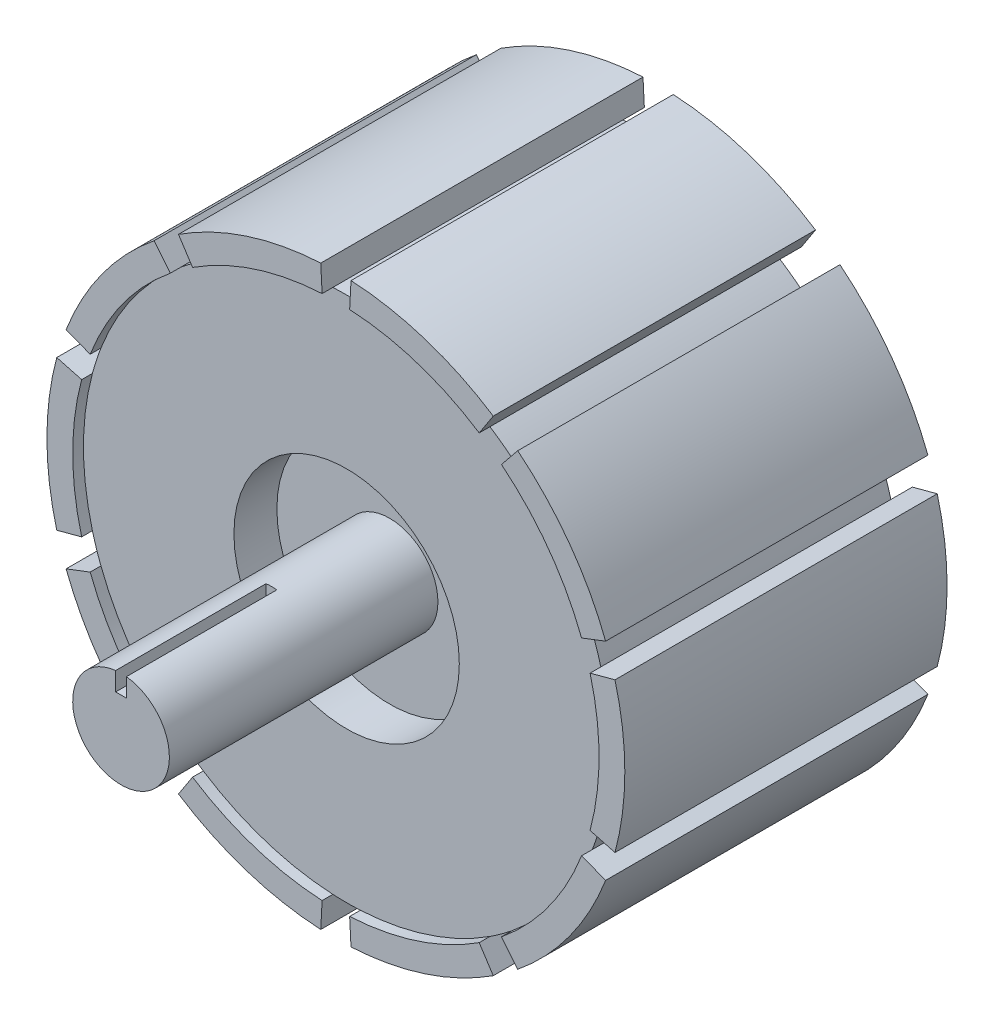
from build123d import *

# Parameters (mm, degrees)
SKETCH1_R           = 24.5
BOSS_EXTRUDE1_DEPTH = 30
SKETCH2_R           = 10.491597787
CUT_EXTRUDE1_DEPTH  = 5
BOSS_EXTRUDE3_DEPTH = 30
SKETCH6_R           = 24.5
CUT_EXTRUDE2_DEPTH  = 2
SKETCH7_R           = 24.5
CUT_EXTRUDE4_DEPTH  = 1
SKETCH4_R           = 4.5
BOSS_EXTRUDE4_DEPTH = 25
CUT_EXTRUDE5_DEPTH  = 14


with BuildPart() as part:
    # Sketch1 → Boss-Extrude1 (new body)
    with BuildSketch(Plane.XY):
        Circle(SKETCH1_R)
    extrude(amount=BOSS_EXTRUDE1_DEPTH)

    # Sketch2 → Cut-Extrude1 (cut)
    with BuildSketch(Plane.XY.offset(30)):
        Circle(SKETCH2_R)
    extrude(amount=-CUT_EXTRUDE1_DEPTH, mode=Mode.SUBTRACT)

    # Sketch5 → Boss-Extrude3 (add)
    with BuildSketch(Plane(origin=(0, 0, 0), x_dir=(-1, 0, 0), z_dir=(0, 0, -1))):
        with BuildLine():
            ThreePointArc((-1.28221594, -24.466424387), (-7.570916362, -23.300884649), (-13.343668945, -20.54742074))
            Line((-13.343668945, -20.54742074), (-14.650803863, -22.560229302))
            ThreePointArc((-14.650803863, -22.560229302), (-8.312557149, -25.583420288), (-1.407820766, -26.863135347))
            Line((-1.407820766, -26.863135347), (-1.28221594, -24.466424387))
        make_face()
        with BuildLine():
            ThreePointArc((13.343668945, -20.54742074), (7.570916362, -23.300884649), (1.28221594, -24.466424387))
            Line((1.28221594, -24.466424387), (1.407820766, -26.863135347))
            ThreePointArc((1.407820766, -26.863135347), (8.312557149, -25.583420288), (14.650803863, -22.560229302))
            Line((14.650803863, -22.560229302), (13.343668945, -20.54742074))
        make_face()
        with BuildLine():
            ThreePointArc((22.872725828, -8.780000752), (19.820916362, -14.400738681), (15.418337917, -19.040085501))
            Line((15.418337917, -19.040085501), (16.928705712, -20.905236734))
            ThreePointArc((16.928705712, -20.905236734), (21.762557149, -15.811423287), (25.113319378, -9.640082458))
            Line((25.113319378, -9.640082458), (22.872725828, -8.780000752))
        make_face()
        with BuildLine():
            Line((25.983400462, 6.962248231), (23.665178859, 6.341081103))
            ThreePointArc((23.665178859, 6.341081103), (24.290398124, 3.19789915), (24.5, 0))
            ThreePointArc((24.5, 0), (24.290398124, -3.19789915), (23.665178859, -6.341081103))
            Line((23.665178859, -6.341081103), (25.983400462, -6.962248231))
            ThreePointArc((25.983400462, -6.962248231), (26.9, 0), (25.983400462, 6.962248231))
        make_face()
        with BuildLine():
            Line((16.928705712, 20.905236734), (15.418337917, 19.040085501))
            ThreePointArc((15.418337917, 19.040085501), (19.820916362, 14.400738681), (22.872725828, 8.780000752))
            Line((22.872725828, 8.780000752), (25.113319378, 9.640082458))
            ThreePointArc((25.113319378, 9.640082458), (21.762557149, 15.811423287), (16.928705712, 20.905236734))
        make_face()
        with BuildLine():
            Line((1.407820766, 26.863135347), (1.28221594, 24.466424387))
            ThreePointArc((1.28221594, 24.466424387), (7.570916362, 23.300884649), (13.343668945, 20.54742074))
            Line((13.343668945, 20.54742074), (14.650803863, 22.560229302))
            ThreePointArc((14.650803863, 22.560229302), (8.312557149, 25.583420288), (1.407820766, 26.863135347))
        make_face()
        with BuildLine():
            Line((-14.650803863, 22.560229302), (-13.343668945, 20.54742074))
            ThreePointArc((-13.343668945, 20.54742074), (-7.570916362, 23.300884649), (-1.28221594, 24.466424387))
            Line((-1.28221594, 24.466424387), (-1.407820766, 26.863135347))
            ThreePointArc((-1.407820766, 26.863135347), (-8.312557149, 25.583420288), (-14.650803863, 22.560229302))
        make_face()
        with BuildLine():
            Line((-25.113319378, 9.640082458), (-22.872725828, 8.780000752))
            ThreePointArc((-22.872725828, 8.780000752), (-19.820916362, 14.400738681), (-15.418337917, 19.040085501))
            Line((-15.418337917, 19.040085501), (-16.928705712, 20.905236734))
            ThreePointArc((-16.928705712, 20.905236734), (-21.762557149, 15.811423287), (-25.113319378, 9.640082458))
        make_face()
        with BuildLine():
            ThreePointArc((-23.665178859, -6.341081103), (-24.5, 0), (-23.665178859, 6.341081103))
            Line((-23.665178859, 6.341081103), (-25.983400462, 6.962248231))
            ThreePointArc((-25.983400462, 6.962248231), (-26.9, 0), (-25.983400462, -6.962248231))
            Line((-25.983400462, -6.962248231), (-23.665178859, -6.341081103))
        make_face()
        with BuildLine():
            ThreePointArc((-15.418337917, -19.040085501), (-19.820916362, -14.400738681), (-22.872725828, -8.780000752))
            Line((-22.872725828, -8.780000752), (-25.113319378, -9.640082458))
            ThreePointArc((-25.113319378, -9.640082458), (-21.762557149, -15.811423287), (-16.928705712, -20.905236734))
            Line((-16.928705712, -20.905236734), (-15.418337917, -19.040085501))
        make_face()
    extrude(amount=-BOSS_EXTRUDE3_DEPTH)

    # Sketch6 → Cut-Extrude2 (cut)
    with BuildSketch(Plane(origin=(0, 0, 0), x_dir=(-1, 0, 0), z_dir=(0, 0, -1))):
        Circle(SKETCH6_R)
    extrude(amount=-CUT_EXTRUDE2_DEPTH, mode=Mode.SUBTRACT)

    # Sketch7 → Cut-Extrude4 (cut)
    with BuildSketch(Plane.XY.offset(30)):
        Circle(SKETCH7_R)
    extrude(amount=-CUT_EXTRUDE4_DEPTH, mode=Mode.SUBTRACT)

    # Sketch4 → Boss-Extrude4 (add)
    with BuildSketch(Plane.XY.offset(25)):
        Circle(SKETCH4_R)
    extrude(amount=BOSS_EXTRUDE4_DEPTH)

    # Sketch8 → Cut-Extrude5 (cut)
    with BuildSketch(Plane.XY.offset(50)):
        with BuildLine():
            Line((-0.5, 2.742191979), (0.5, 2.742191979))
            Line((0.5, 2.742191979), (0.5, 4.472135955))
            ThreePointArc((0.5, 4.472135955), (0, 4.5), (-0.5, 4.472135955))
            Line((-0.5, 4.472135955), (-0.5, 2.742191979))
        make_face()
    extrude(amount=-CUT_EXTRUDE5_DEPTH, mode=Mode.SUBTRACT)


solid = part.part
